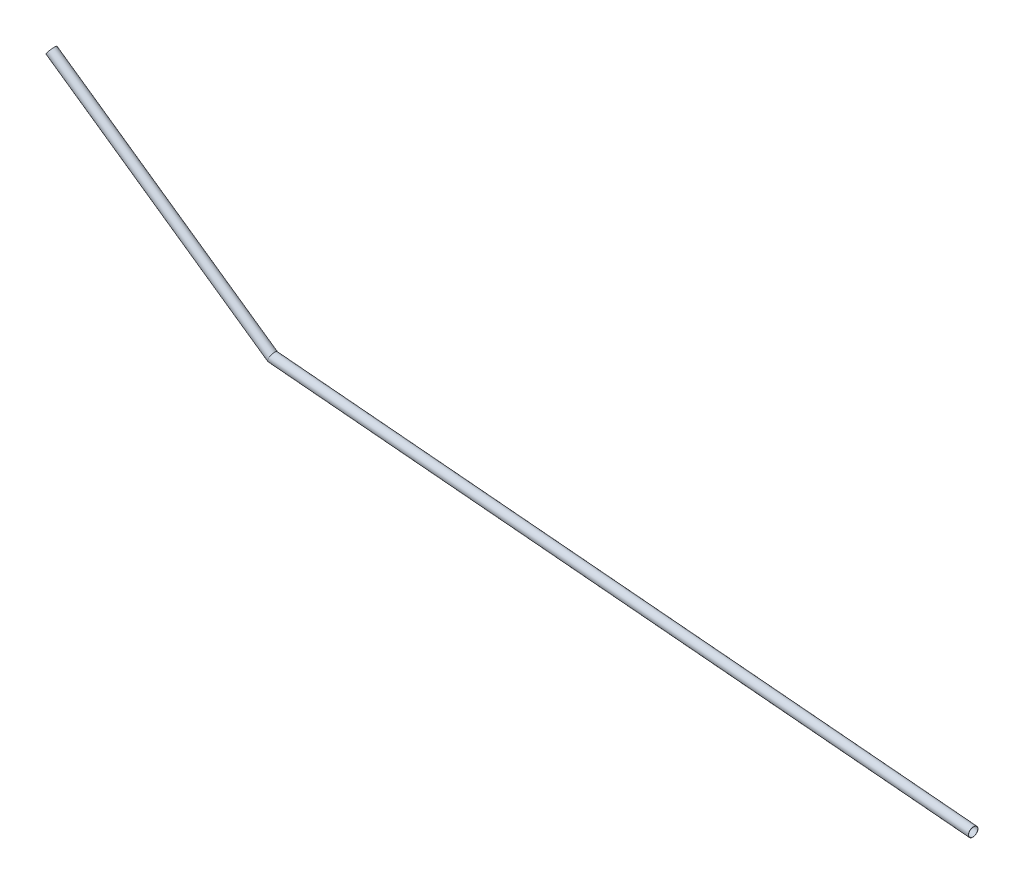
from build123d import *

# Parameters (mm, degrees)
SKETCH3_R   = 2.6
SKETCH3_R_2 = 2.5


with BuildPart() as part:
    # Sweep-Thin1: sweep along a path in Sketch2
    with BuildLine(Plane.XY) as sweep_thin1_path:
        Line((0, 0), (380, 33.24569214))
        Line((380, 33.24569214), (500, 117.270596725))
    # Sketch3 → Sweep-Thin1 (sweep)
    with BuildSketch(Plane(origin=(0, 0, 0), x_dir=(0, 0, -1), z_dir=(0.996194698, 0.087155743, 0))):
        Circle(SKETCH3_R)
        Circle(SKETCH3_R_2, mode=Mode.SUBTRACT)
    sweep(path=sweep_thin1_path.line, transition=Transition.RIGHT)


with BuildPart() as body_2:
    # Mirror1: mirrored copy
    add(part.part.mirror(Plane(origin=(0, 0, 0), x_dir=(0, 0, 1), z_dir=(1, 0, 0))))


solid = body_2.part
